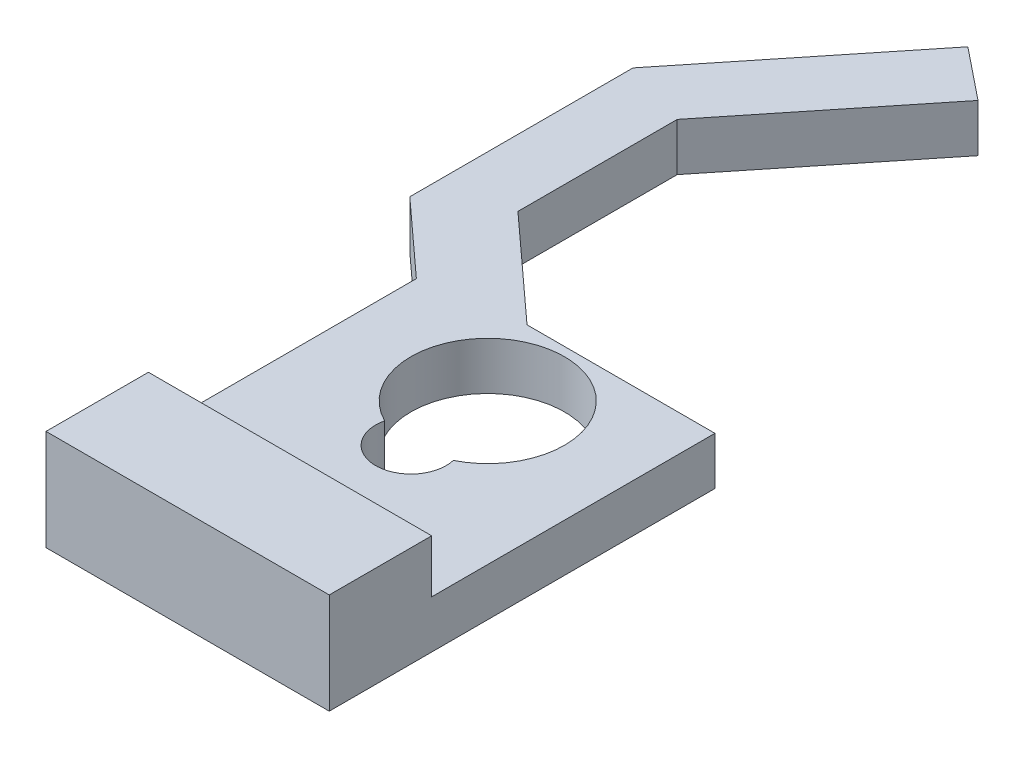
from build123d import *

# Parameters (mm, degrees)
RESSALTO_EXTRUS_O1_DEPTH = 1.4
ESBO_O2_R                = 3.45
RESSALTO_EXTRUS_O2_DEPTH = 2.4
FURO4_D                  = 1.2
PADR_O_LINEAR1_COUNT     = 6
PADR_O_LINEAR1_PITCH     = 2
FURO1_D                  = 4.95
FURO1_DEPTH              = 2
FURO2_D                  = 4.6
FURO2_DEPTH              = 1
FURO3_D                  = 2.1
RESSALTO_EXTRUS_O3_DEPTH = 2
PADR_OCIRCULAR1_COUNT    = 60
CUT_EXTRUDE1_DEPTH       = 10
BOSS_EXTRUDE1_DEPTH      = 3.8
SKETCH4_W                = 22.5
SKETCH4_H                = 22.5
BOSS_EXTRUDE2_DEPTH      = 3.8
SKETCH5_R                = 6.1
SKETCH5_R_2              = 2.8
CUT_EXTRUDE2_DEPTH       = 10
SKETCH6_W                = 22.5
SKETCH6_H                = 8.135993376
BOSS_EXTRUDE3_DEPTH      = 8


with BuildPart() as part:
    # Esboço1 → Ressalto-extrusão1 (new body)
    with BuildSketch(Plane(origin=(0, 0, 0), x_dir=(1, 0, 0), z_dir=(0, 1, 0))):
        with BuildLine():
            Line((-14.159121967, 1.99702088), (-2.209072203, 2.65))
            ThreePointArc((-2.209072203, 2.65), (3.45, 0), (-2.209072203, -2.65))
            Line((-2.209072203, -2.65), (-14.159121967, -1.99702088))
            ThreePointArc((-14.159121967, -1.99702088), (-16.05, 0), (-14.159121967, 1.99702088))
        make_face()
    extrude(amount=-RESSALTO_EXTRUS_O1_DEPTH)

    # Esboço2 → Ressalto-extrusão2 (add)
    with BuildSketch(Plane.XZ.offset(1.4)):
        Circle(ESBO_O2_R)
    extrude(amount=RESSALTO_EXTRUS_O2_DEPTH)

    # Furo4 (through all)
    with Locations(Plane(origin=(0, 0, 0), x_dir=(1, 0, 0), z_dir=(0, 1, 0))):
        with Locations((-14.45, 0)):
            furo4 = Hole(FURO4_D / 2)

    # Padrão linear1: Furo4 ×6
    with Locations(*[(i * PADR_O_LINEAR1_PITCH, 0, 0) for i in range(1, PADR_O_LINEAR1_COUNT)]):
        add(furo4, mode=Mode.SUBTRACT)

    # Furo1
    with Locations(Plane(origin=(0, -3.8, 0), x_dir=(-1, 0, 0), z_dir=(0, -1, 0))):
        with Locations((0, 0)):
            Hole(FURO1_D / 2, depth=FURO1_DEPTH)

    # Furo2
    with Locations(Plane(origin=(0, 0, 0), x_dir=(1, 0, 0), z_dir=(0, 1, 0))):
        with Locations((0, 0)):
            Hole(FURO2_D / 2, depth=FURO2_DEPTH)

    # Furo3 (through all)
    with Locations(Plane(origin=(0, 0, 0), x_dir=(1, 0, 0), z_dir=(0, 1, 0))):
        with Locations((0, 0)):
            Hole(FURO3_D / 2)

    # Esboço11 → Ressalto-extrusão3 (add)
    with BuildSketch(Plane.XZ.offset(3.8)):
        with BuildLine():
            Line((-0.098056786, 2.473056786), (0, 2.375))
            Line((0, 2.375), (0.098056786, 2.473056786))
            ThreePointArc((0.098056786, 2.473056786), (0, 2.475), (-0.098056786, 2.473056786))
        make_face()
    ressalto_extrus_o3 = extrude(amount=-RESSALTO_EXTRUS_O3_DEPTH)

    # PadrãoCircular1: Ressalto-extrusão3 ×60 about axis
    padr_ocircular1_axis = Axis((0, 0, 0), (0, 1, 0))
    for i in range(1, PADR_OCIRCULAR1_COUNT):
        add(ressalto_extrus_o3.rotate(padr_ocircular1_axis, i * 360 / PADR_OCIRCULAR1_COUNT))

    # Sketch1 → Cut-Extrude1 (cut)
    with BuildSketch(Plane.XZ.offset(3.8)):
        with BuildLine():
            Line((0, 3.45), (-16.05, 3.45))
            Line((-16.05, 3.45), (-16.05, -3.45))
            Line((-16.05, -3.45), (0, -3.45))
            ThreePointArc((0, -3.45), (-3.45, 0), (0, 3.45))
        make_face()
    extrude(amount=-CUT_EXTRUDE1_DEPTH, mode=Mode.SUBTRACT)

    # Sketch2 → Boss-Extrude1 (add)
    with BuildSketch(Plane(origin=(0, 0, 0), x_dir=(1, 0, 0), z_dir=(0, 1, 0))):
        with BuildLine():
            Line((0, 3.45), (-11.841431407, 14.240980385))
            Line((-11.841431407, 14.240980385), (-11.841431407, 26.898431862))
            Line((-11.841431407, 26.898431862), (-1.20031972, 40.147481011))
            Line((-1.20031972, 40.147481011), (-5.293722372, 43.435139945))
            Line((-5.293722372, 43.435139945), (-17.141431407, 28.683779004))
            Line((-17.141431407, 28.683779004), (-17.141431407, 10.953171381))
            Line((-17.141431407, 10.953171381), (-2.323790008, -2.55))
            ThreePointArc((-2.323790008, -2.55), (-3.217141588, 1.245993579), (0, 3.45))
        make_face()
    extrude(amount=-BOSS_EXTRUDE1_DEPTH)

    # Sketch4 → Boss-Extrude2 (add)
    with BuildSketch(Plane.XZ.offset(3.8)):
        with Locations((0, 4.45)):
            Rectangle(SKETCH4_W, SKETCH4_H)
    extrude(amount=-BOSS_EXTRUDE2_DEPTH)

    # Sketch5 → Cut-Extrude2 (cut)
    with BuildSketch(Plane.XZ.offset(3.8)):
        Circle(SKETCH5_R)
        with Locations((0, 6.1)):
            Circle(SKETCH5_R_2)
    extrude(amount=-CUT_EXTRUDE2_DEPTH, mode=Mode.SUBTRACT)

    # Sketch6 → Boss-Extrude3 (add)
    with BuildSketch(Plane.XZ.offset(3.8)):
        with Locations((0, 19.767996688)):
            Rectangle(SKETCH6_W, SKETCH6_H)
    extrude(amount=-BOSS_EXTRUDE3_DEPTH)


solid = part.part
